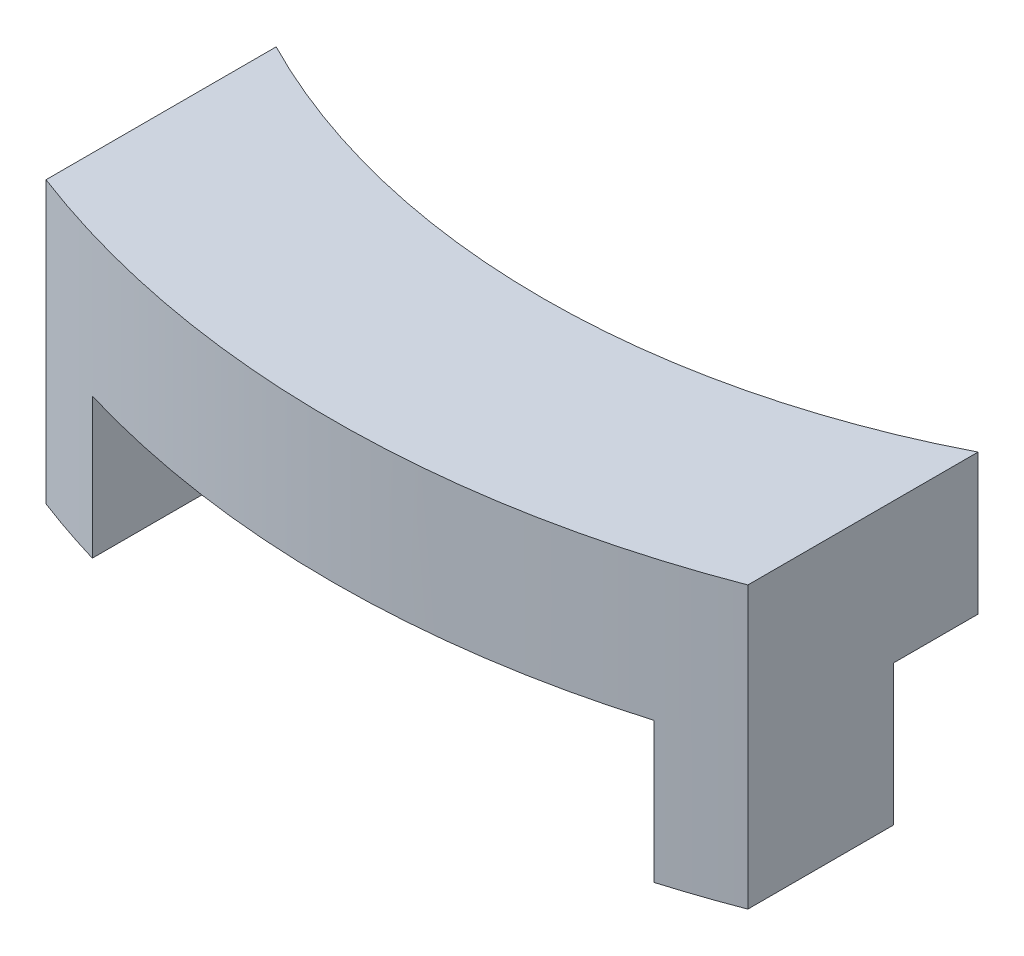
from build123d import *

# Parameters (mm, degrees)
BOSS_EXTRUDE1_DEPTH = 2
BOSS_EXTRUDE2_DEPTH = 2


with BuildPart() as part:
    # Sketch1 → Boss-Extrude1 (new body)
    with BuildSketch(Plane(origin=(0, 0, 0), x_dir=(1, 0, 0), z_dir=(0, 1, 0))):
        with BuildLine():
            Line((-5, -9.797958971), (-5, -13.076696831))
            ThreePointArc((-5, -13.076696831), (0, -14), (5, -13.076696831))
            Line((5, -13.076696831), (5, -9.797958971))
            ThreePointArc((5, -9.797958971), (0, -11), (-5, -9.797958971))
        make_face()
    extrude(amount=BOSS_EXTRUDE1_DEPTH)

    # Sketch3 → Boss-Extrude2 (add)
    with BuildSketch(Plane.XZ):
        with BuildLine():
            Line((5, 13.076696831), (5, 11))
            Line((5, 11), (4, 11))
            Line((4, 11), (4, 13.416407865))
            ThreePointArc((4, 13.416407865), (4.503204514, 13.255985407), (5, 13.076696831))
        make_face()
        with BuildLine():
            Line((-5, 11), (-5, 13.076696831))
            ThreePointArc((-5, 13.076696831), (-4.503204514, 13.255985407), (-4, 13.416407865))
            Line((-4, 13.416407865), (-4, 11))
            Line((-4, 11), (-5, 11))
        make_face()
    extrude(amount=BOSS_EXTRUDE2_DEPTH)


solid = part.part
